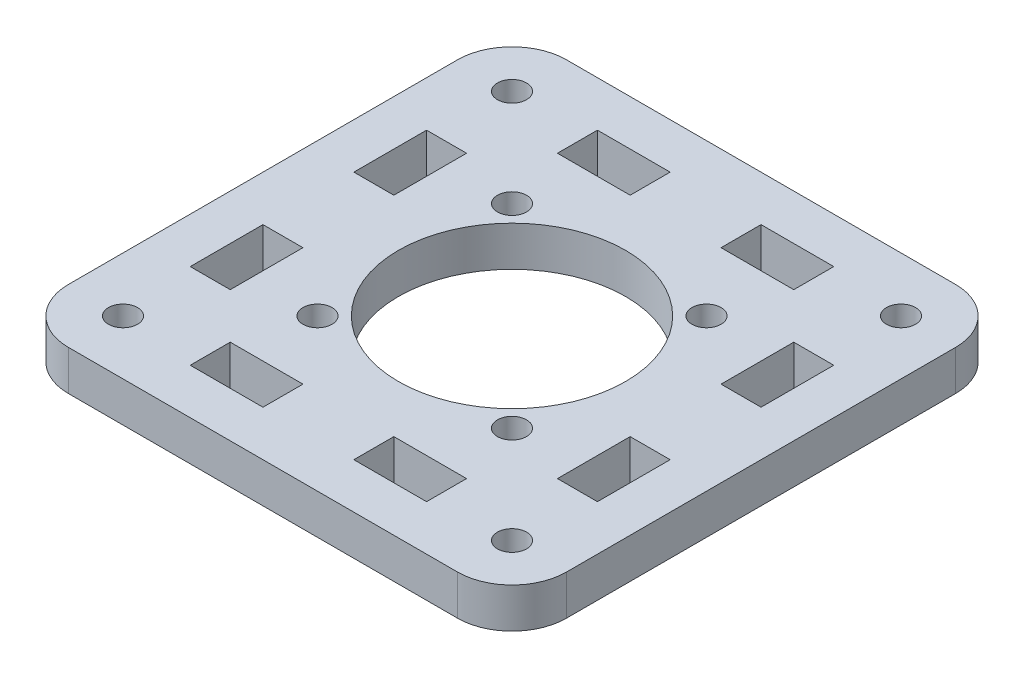
from build123d import *

# Parameters (mm, degrees)
SKETCH_1_W          = 54.8
SKETCH_1_H          = 54.8
SKETCH_1_R          = 12.5
SKETCH_1_R_2        = 1.6
SKETCH_1_W_2        = 4.4
SKETCH_1_H_2        = 8
SKETCH_1_W_3        = 8
SKETCH_1_H_3        = 4.4
EXTRUDE_1_DEPTH     = 4.4
FILLET_1_R          = 6
SKETCH_2_R          = 1.6
CUT_EXTRUDE_1_DEPTH = 10


with BuildPart() as part:
    # 草图1 → 凸台-拉伸1 (new body)
    with BuildSketch(Plane(origin=(0, 0, 0), x_dir=(1, 0, 0), z_dir=(0, 1, 0))):
        Rectangle(SKETCH_1_W, SKETCH_1_H)
        Circle(SKETCH_1_R, mode=Mode.SUBTRACT)
        with Locations((21.4, 21.4)):
            Circle(SKETCH_1_R_2, mode=Mode.SUBTRACT)
        with Locations((21.4, -21.4)):
            Circle(SKETCH_1_R_2, mode=Mode.SUBTRACT)
        with Locations((-21.4, -21.4)):
            Circle(SKETCH_1_R_2, mode=Mode.SUBTRACT)
        with Locations((-21.4, 21.4)):
            Circle(SKETCH_1_R_2, mode=Mode.SUBTRACT)
        with Locations((20.2, 9)):
            Rectangle(SKETCH_1_W_2, SKETCH_1_H_2, mode=Mode.SUBTRACT)
        with Locations((20.2, -9)):
            Rectangle(SKETCH_1_W_2, SKETCH_1_H_2, mode=Mode.SUBTRACT)
        with Locations((-20.2, -9)):
            Rectangle(SKETCH_1_W_2, SKETCH_1_H_2, mode=Mode.SUBTRACT)
        with Locations((-20.2, 9)):
            Rectangle(SKETCH_1_W_2, SKETCH_1_H_2, mode=Mode.SUBTRACT)
        with Locations((9, 20.2)):
            Rectangle(SKETCH_1_W_3, SKETCH_1_H_3, mode=Mode.SUBTRACT)
        with Locations((9, -20.2)):
            Rectangle(SKETCH_1_W_3, SKETCH_1_H_3, mode=Mode.SUBTRACT)
        with Locations((-9, -20.2)):
            Rectangle(SKETCH_1_W_3, SKETCH_1_H_3, mode=Mode.SUBTRACT)
        with Locations((-9, 20.2)):
            Rectangle(SKETCH_1_W_3, SKETCH_1_H_3, mode=Mode.SUBTRACT)
    extrude(amount=EXTRUDE_1_DEPTH)

    # 圆角1
    fillet_1_edges = [part.edges().sort_by_distance(p)[0] for p in [
        (27.4, 2.2, 27.4),
        (-27.4, 2.2, 27.4),
        (-27.4, 2.2, -27.4),
        (27.4, 2.2, -27.4),
    ]]
    fillet(fillet_1_edges, radius=FILLET_1_R)

    # 草图2 → 切除-拉伸1 (cut)
    with BuildSketch(Plane(origin=(0, 4.4, 0), x_dir=(1, 0, 0), z_dir=(0, 1, 0))):
        with Locations((10.7, 10.7)):
            Circle(SKETCH_2_R)
        with Locations((10.7, -10.7)):
            Circle(SKETCH_2_R)
        with Locations((-10.7, -10.7)):
            Circle(SKETCH_2_R)
        with Locations((-10.7, 10.7)):
            Circle(SKETCH_2_R)
    extrude(amount=-CUT_EXTRUDE_1_DEPTH, mode=Mode.SUBTRACT)


solid = part.part
